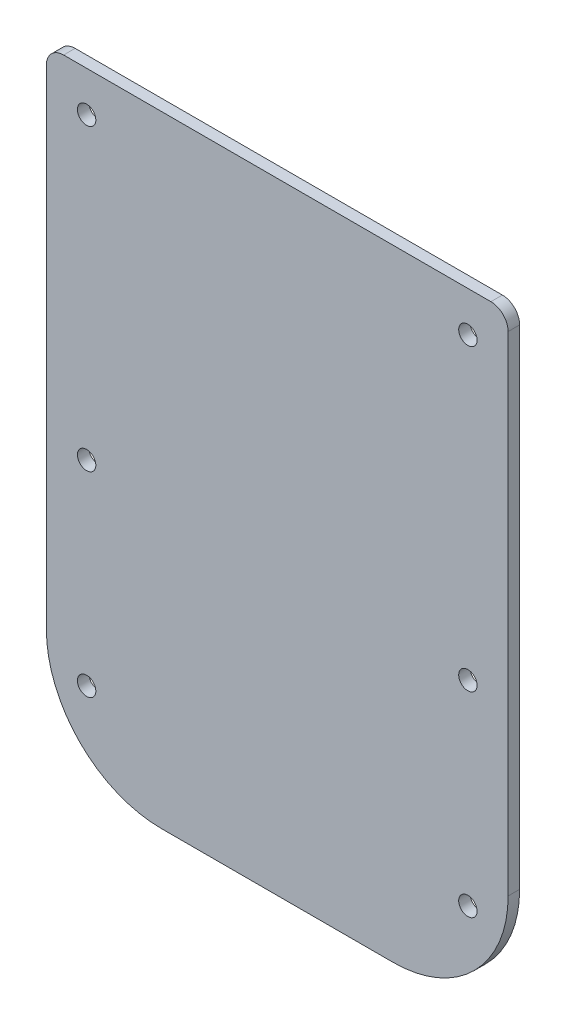
from build123d import *

# Parameters (mm, degrees)
SKETCH1_W                      = 80.3
SKETCH1_H                      = 66
BOSS_EXTRUDE1_DEPTH            = 2
F_3_2_3_2_DIAMETER_HOLE1_D     = 3.2
FILLET1_R                      = 3
SKETCH4_W                      = 80.3
SKETCH4_H                      = 2
BOSS_EXTRUDE2_DEPTH            = 42
FILLET2_R                      = 20
F_3_2_3_2_DIAMETER_HOLE2_D     = 3.2
F_3_2_3_2_DIAMETER_HOLE2_DEPTH = 60
F_3_2_3_2_DIAMETER_HOLE2_TIP   = 0.96137699


with BuildPart() as part:
    # Sketch1 → Boss-Extrude1 (new body)
    with BuildSketch(Plane.XY):
        with Locations((40.15, 33)):
            Rectangle(SKETCH1_W, SKETCH1_H)
    extrude(amount=BOSS_EXTRUDE1_DEPTH)

    # Ø3.2 (3.2) Diameter Hole1 (through all)
    with Locations(Plane.XY.offset(2)):
        with Locations((7, 59), (73.3, 59), (73.3, 7), (7, 7)):
            Hole(F_3_2_3_2_DIAMETER_HOLE1_D / 2)

    # Fillet1
    fillet1_edges = [part.edges().sort_by_distance(p)[0] for p in [
        (0, 66, 1),
        (80.3, 66, 1),
    ]]
    fillet(fillet1_edges, radius=FILLET1_R)

    # Sketch4 → Boss-Extrude2 (add)
    with BuildSketch(Plane.XZ):
        with Locations((40.15, 1)):
            Rectangle(SKETCH4_W, SKETCH4_H)
    extrude(amount=BOSS_EXTRUDE2_DEPTH)

    # Fillet2
    fillet2_edges = [part.edges().sort_by_distance(p)[0] for p in [
        (0, -42, 1),
        (80.3, -42, 1),
    ]]
    fillet(fillet2_edges, radius=FILLET2_R)

    # Ø3.2 (3.2) Diameter Hole2
    with Locations(Plane.XY.offset(2)):
        with Locations((7, -27), (73.3, -27)):
            Hole(F_3_2_3_2_DIAMETER_HOLE2_D / 2, depth=F_3_2_3_2_DIAMETER_HOLE2_DEPTH)
            with Locations((0, 0, -(F_3_2_3_2_DIAMETER_HOLE2_DEPTH + F_3_2_3_2_DIAMETER_HOLE2_TIP / 2))):  # 118° drill point
                Cone(0, F_3_2_3_2_DIAMETER_HOLE2_D / 2, F_3_2_3_2_DIAMETER_HOLE2_TIP, mode=Mode.SUBTRACT)


solid = part.part
